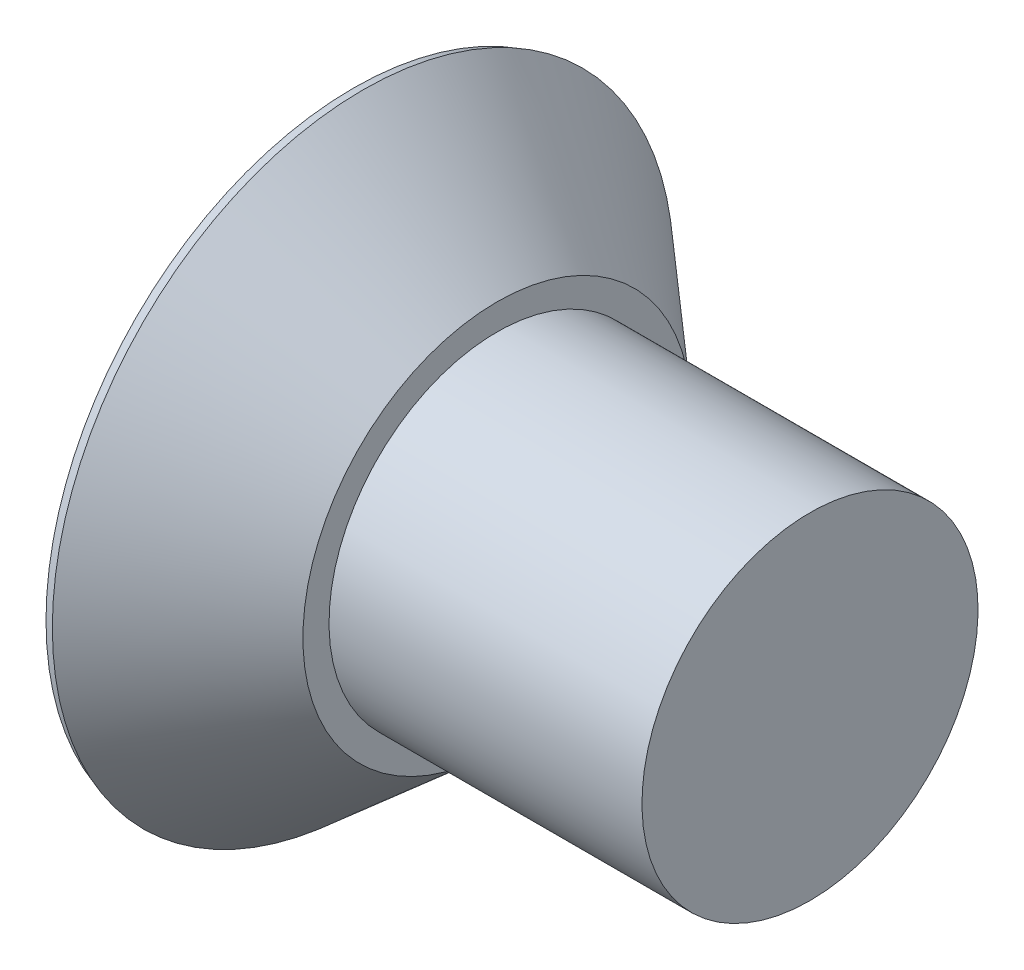
from build123d import *

# Parameters (mm, degrees)
CUT_EXTRUDE1_REACH = 8.695
CIRPATTERN1_COUNT  = 4
DRAFT1_ANGLE       = 5
CHAMFER1_SIZE      = 0.133096
CHAMFER1_SIZE2     = 0.121906137


with BuildPart() as part:
    # Sketch2 → Revolve1 (revolve)
    with BuildSketch(Plane.XY, mode=Mode.PRIVATE) as revolve1_sk:
        Polygon((-2.38125, 0), (2.38125, 0), (2.38125, 1.7526), (-0.88265, 1.7526), (-0.88265, 2.024686895), (-2.38125, 3.3274), align=None)
    revolve(revolve1_sk.sketch.rotate(Axis((-2.38125, 0, 0), (1, 0, 0)), 180), axis=Axis((-2.38125, 0, 0), (1, 0, 0)))

    # Cut-Extrude1: up to this cone (the profile starts inside it)
    cut_extrude1_end = Plane(origin=(-2.38125, 0, 0), z_dir=(-1, 0, 0)).offset(-2.137134931) * Cone(1e-06, 11.465822401, 13.189918853, align=(Align.CENTER, Align.CENTER, Align.MIN), mode=Mode.PRIVATE)
    # Sketch3 → Cut-Extrude1 (cut, up to the surface)
    with BuildSketch(Plane.ZY.offset(2.38125), mode=Mode.PRIVATE) as cut_extrude1_sk1:
        with BuildLine():
            Line((0, 0), (2.218266667, 0))
            ThreePointArc((2.218266667, 0), (2.207033704, 0.22295568), (2.173448579, 0.443653333))
            Line((2.173448579, 0.443653333), (1.308550956, 0.443653333))
            Line((1.308550956, 0.443653333), (0.696975982, 0.696975982))
            Line((0.696975982, 0.696975982), (0.443653333, 1.308550956))
            Line((0.443653333, 1.308550956), (0.443653333, 2.173448579))
            ThreePointArc((0.443653333, 2.173448579), (0.22295568, 2.207033704), (0, 2.218266667))
            Line((0, 2.218266667), (0, 0))
        make_face()
    cut_extrude1_tool1 = extrude(cut_extrude1_sk1.sketch, amount=-CUT_EXTRUDE1_REACH, mode=Mode.PRIVATE) & cut_extrude1_end
    cut_extrude1 = cut_extrude1_tool1.solids().sort_by_distance((-2.38125, 1.109133, 0.031371))[0]
    add(cut_extrude1, mode=Mode.SUBTRACT)

    # CirPattern1: Cut-Extrude1 ×4 about axis
    cirpattern1_axis = Axis((0, 0, 0), (1, 0, 0))
    for i in range(1, CIRPATTERN1_COUNT):
        add(cut_extrude1.rotate(cirpattern1_axis, i * 360 / CIRPATTERN1_COUNT), mode=Mode.SUBTRACT)

    # Draft1
    draft1_faces = [part.faces().sort_by_distance(p)[0] for p in [
        (-2.19829002, 0.443653333, -1.474018434),
        (-1.970823894, 0.582482874, -0.973386795),
        (-1.970823894, 0.973386795, -0.582482874),
        (-2.19829002, 1.474018434, -0.443653333),
        (-2.19829002, 1.474018434, 0.443653333),
        (-1.970823894, 0.973386795, 0.582482874),
        (-1.970823894, 0.582482874, 0.973386795),
        (-2.19829002, 0.443653333, 1.474018434),
        (-2.19829002, -0.443653333, 1.474018434),
        (-1.970823894, -0.582482874, 0.973386795),
        (-1.970823894, -0.973386795, 0.582482874),
        (-2.19829002, -1.474018434, 0.443653333),
        (-2.19829002, -1.474018434, -0.443653333),
        (-1.970823894, -0.973386795, -0.582482874),
        (-1.970823894, -0.582482874, -0.973386795),
        (-2.19829002, -0.443653333, -1.474018434),
    ]]
    draft(draft1_faces, Plane(origin=(-2.38125, 0, 0), x_dir=(0, -1, 0), z_dir=(-1, 0, 0)), DRAFT1_ANGLE)

    # Chamfer1
    chamfer1_edges = [part.edges().sort_by_distance(p)[0] for p in [
        (-2.38125, 3.3274, 0),
    ]]
    chamfer1_side = [part.faces().sort_by_distance(p)[0] for p in [
        (-1.63195, 2.676043447, 0),
    ]]
    chamfer(chamfer1_edges, length=CHAMFER1_SIZE, length2=CHAMFER1_SIZE2, reference=chamfer1_side[0])


solid = part.part
